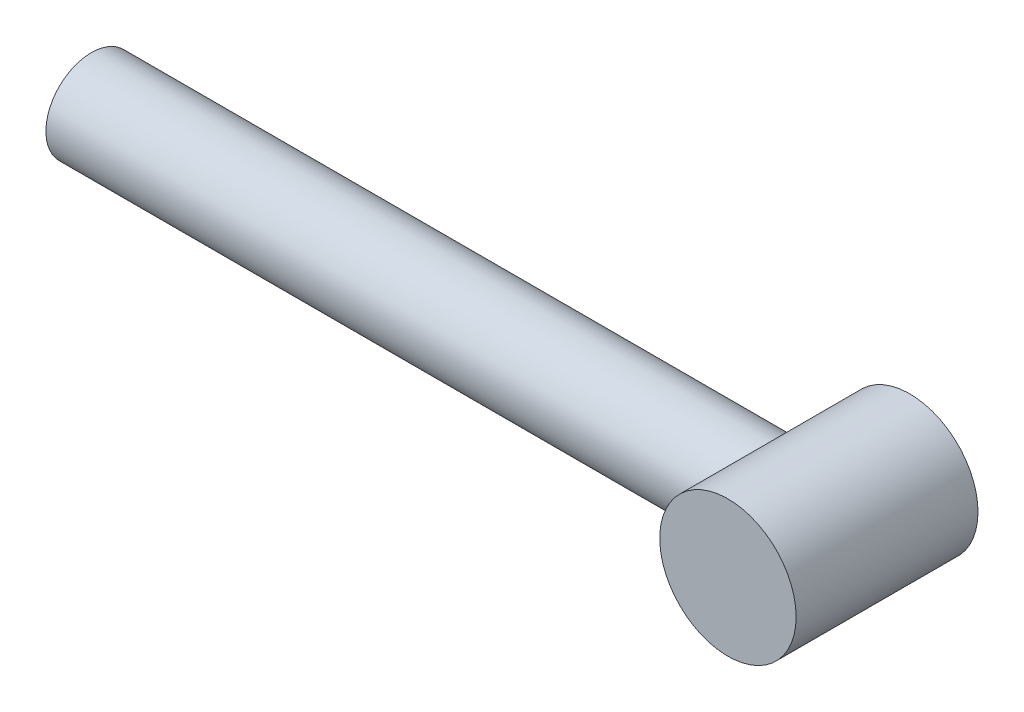
from build123d import *

# Parameters (mm, degrees)
SKETCH1_R                         = 2.38125
BRAKE_CABLE_ANCHOR_CYLINDER_DEPTH = 3.175
SKETCH3_R                         = 1.5875
BRAKE_CABLE_SIMULATED_DEPTH       = 25.4


with BuildPart() as part:
    # Sketch1 → Brake Cable Anchor Cylinder (new body, symmetric)
    with BuildSketch(Plane.XY):
        Circle(SKETCH1_R)
    extrude(amount=BRAKE_CABLE_ANCHOR_CYLINDER_DEPTH, both=True)

    # Sketch3 → Brake Cable (simulated) (add)
    with BuildSketch(Plane(origin=(0, 0, 0), x_dir=(0, 0, -1), z_dir=(1, 0, 0))):
        Circle(SKETCH3_R)
    extrude(amount=-BRAKE_CABLE_SIMULATED_DEPTH)


solid = part.part
